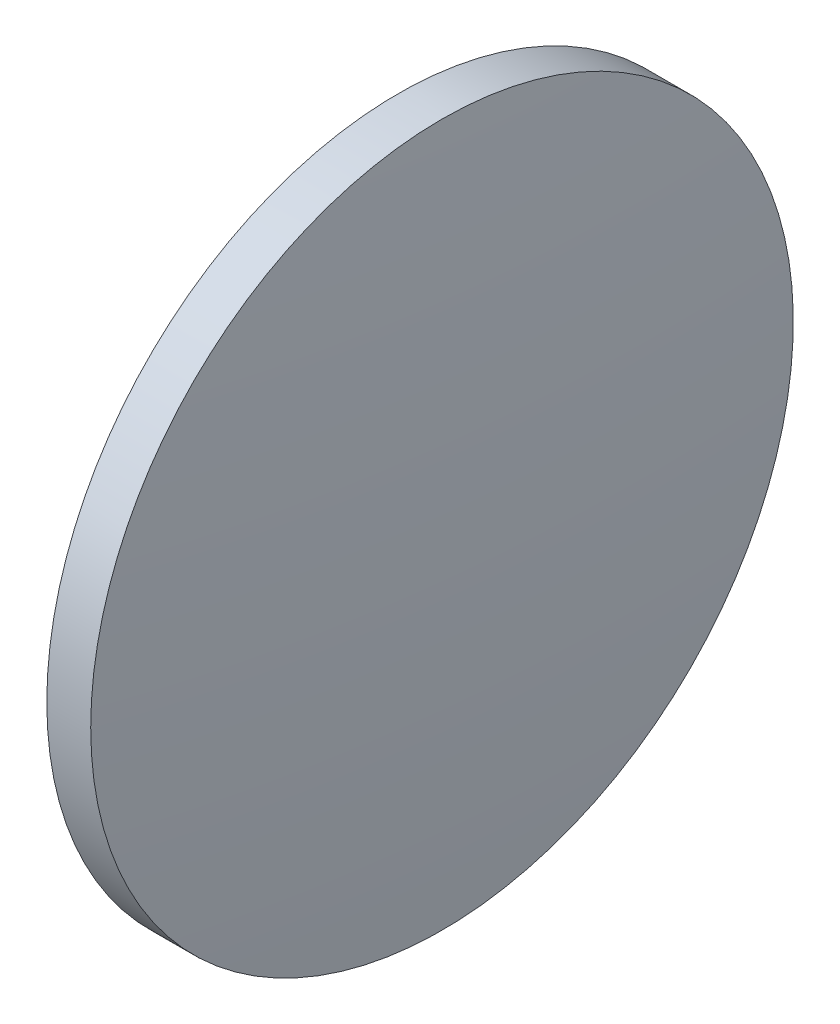
from build123d import *


with BuildPart() as part:
    # 草图2 → 旋转2 (revolve)
    with BuildSketch(Plane.XY):
        with BuildLine():
            Line((1332.934272125, 411.587429833), (1332.934272125, 431.587429833))
            Line((1332.934272125, 431.587429833), (1335.434272125, 431.587429833))
            ThreePointArc((1335.434272125, 431.587429833), (1336.019198032, 421.595031944), (1336.214272125, 411.587429833))
            Line((1336.214272125, 411.587429833), (1332.934272125, 411.587429833))
        make_face()
    revolve(axis=Axis((1328.239728944, 411.587429833, 0), (1, 0, 0)))


solid = part.part
